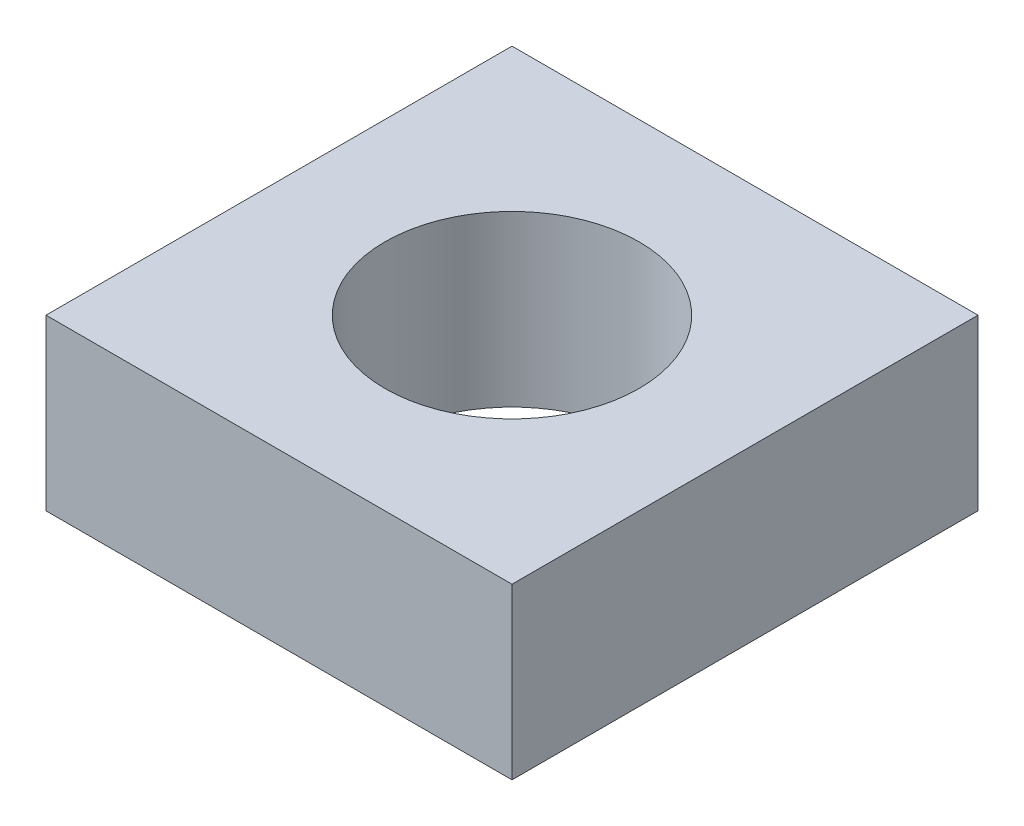
from build123d import *

# Parameters (mm, degrees)
SKETCH_1_W          = 5.5
SKETCH_1_H          = 5.5
EXTRUDE_1_DEPTH     = 2
SKETCH_2_R          = 1.5
CUT_EXTRUDE_1_DEPTH = 3


with BuildPart() as part:
    # 草图1 → 凸台-拉伸1 (new body)
    with BuildSketch(Plane(origin=(0, 0, 0), x_dir=(1, 0, 0), z_dir=(0, 1, 0))):
        Rectangle(SKETCH_1_W, SKETCH_1_H)
    extrude(amount=EXTRUDE_1_DEPTH)

    # 草图2 → 切除-拉伸1 (cut, through all)
    with BuildSketch(Plane(origin=(0, 2, 0), x_dir=(1, 0, 0), z_dir=(0, 1, 0))):
        Circle(SKETCH_2_R)
    extrude(amount=-CUT_EXTRUDE_1_DEPTH, mode=Mode.SUBTRACT)


solid = part.part
